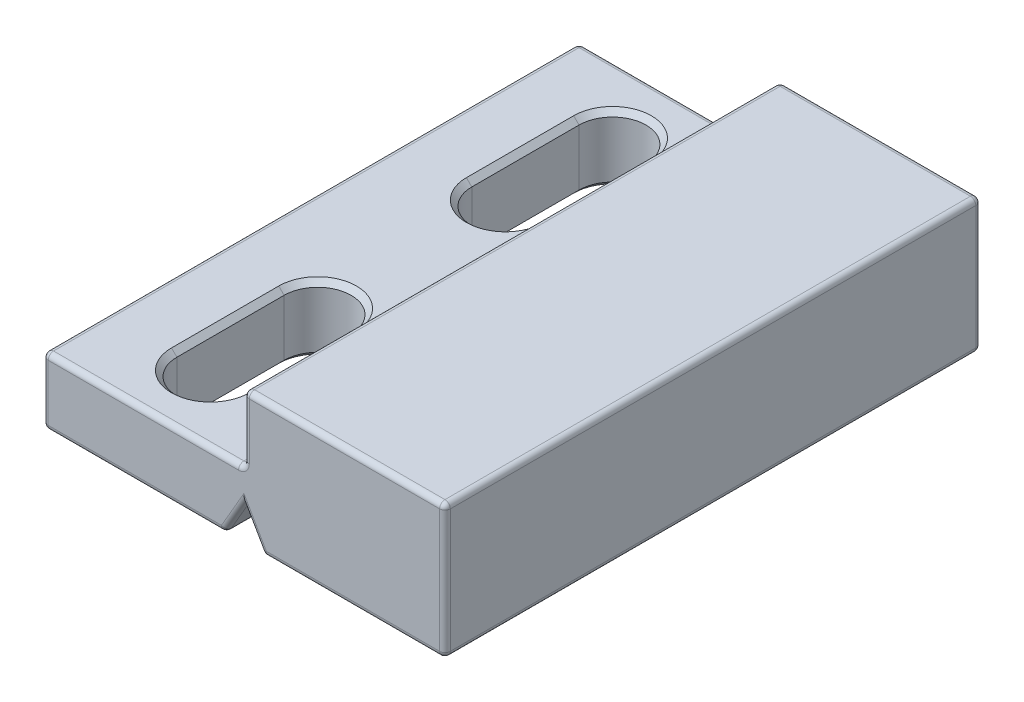
from build123d import *

# Parameters (mm, degrees)
SKETCH1_W           = 19.05
SKETCH1_H           = 25.4
BOSS_EXTRUDE1_DEPTH = 6.35
SKETCH2_W           = 9.525
SKETCH2_H           = 25.4
CUT_EXTRUDE1_DEPTH  = 3.175
CUT_EXTRUDE2_DEPTH  = 33.378773911
CUT_EXTRUDE3_DEPTH  = 32.908355097
FILLET1_R           = 0.254
CHAMFER1_SIZE       = 0.254


with BuildPart() as part:
    # Sketch1 → Boss-Extrude1 (new body)
    with BuildSketch(Plane(origin=(0, 0, 0), x_dir=(1, 0, 0), z_dir=(0, 1, 0))):
        with Locations((9.525, 12.7)):
            Rectangle(SKETCH1_W, SKETCH1_H)
    extrude(amount=BOSS_EXTRUDE1_DEPTH)

    # Sketch2 → Cut-Extrude1 (cut)
    with BuildSketch(Plane(origin=(0, 6.35, 0), x_dir=(1, 0, 0), z_dir=(0, 1, 0))):
        with Locations((4.7625, 12.7)):
            Rectangle(SKETCH2_W, SKETCH2_H)
    extrude(amount=-CUT_EXTRUDE1_DEPTH, mode=Mode.SUBTRACT)

    # Sketch3 → Cut-Extrude2 (cut, through all)
    with BuildSketch(Plane.XY):
        Polygon((8.608456448, 0), (9.525, 1.5875), (10.441543552, 0), align=None)
    extrude(amount=-CUT_EXTRUDE2_DEPTH, mode=Mode.SUBTRACT)

    # Sketch4 → Cut-Extrude3 (cut, through all)
    with BuildSketch(Plane(origin=(0, 3.175, 0), x_dir=(1, 0, 0), z_dir=(0, 1, 0))):
        with BuildLine():
            Line((6.35, 22.225), (6.35, 17.145))
            ThreePointArc((6.35, 17.145), (4.7625, 15.5575), (3.175, 17.145))
            Line((3.175, 17.145), (3.175, 22.225))
            ThreePointArc((3.175, 22.225), (4.7625, 23.8125), (6.35, 22.225))
        make_face()
        with BuildLine():
            Line((6.35, 8.255), (6.35, 3.175))
            ThreePointArc((6.35, 3.175), (4.7625, 1.5875), (3.175, 3.175))
            Line((3.175, 3.175), (3.175, 8.255))
            ThreePointArc((3.175, 8.255), (4.7625, 9.8425), (6.35, 8.255))
        make_face()
    extrude(amount=-CUT_EXTRUDE3_DEPTH, mode=Mode.SUBTRACT)

    # Fillet1
    fillet1_edges = [part.edges().sort_by_distance(p)[0] for p in [
        (19.05, 0, -12.7),
        (10.441543552, 0, -12.7),
        (14.745771776, 0, -25.4),
        (19.05, 3.175, -25.4),
        (9.525, 4.7625, -25.4),
        (4.7625, 3.175, -25.4),
        (0, 1.5875, -25.4),
        (4.304228224, 0, -25.4),
        (9.066728224, 0.79375, -25.4),
        (9.983271776, 0.79375, -25.4),
        (0, 1.5875, 0),
        (4.7625, 3.175, 0),
        (9.525, 4.7625, 0),
        (19.05, 3.175, 0),
        (14.745771776, 0, 0),
        (9.983271776, 0.79375, 0),
        (9.066728224, 0.79375, 0),
        (4.304228224, 0, 0),
        (19.05, 6.35, -12.7),
        (14.2875, 6.35, 0),
        (9.525, 6.35, -12.7),
        (14.2875, 6.35, -25.4),
        (0, 3.175, -12.7),
        (0, 0, -12.7),
        (8.608456448, 0, -12.7),
        (9.525, 3.175, -12.7),
    ]]
    fillet(fillet1_edges, radius=FILLET1_R)

    # Chamfer1
    chamfer1_edges = [part.edges().sort_by_distance(p)[0] for p in [
        (3.175, 0, -19.685),
        (4.7625, 0, -15.5575),
        (4.7625, 0, -23.8125),
        (6.35, 0, -19.685),
        (3.175, 3.175, -19.685),
        (4.7625, 3.175, -15.5575),
        (4.7625, 3.175, -23.8125),
        (6.35, 3.175, -19.685),
        (3.175, 0, -5.715),
        (4.7625, 0, -1.5875),
        (4.7625, 0, -9.8425),
        (6.35, 0, -5.715),
        (3.175, 3.175, -5.715),
        (4.7625, 3.175, -1.5875),
        (4.7625, 3.175, -9.8425),
        (6.35, 3.175, -5.715),
    ]]
    chamfer(chamfer1_edges, length=CHAMFER1_SIZE)


solid = part.part
